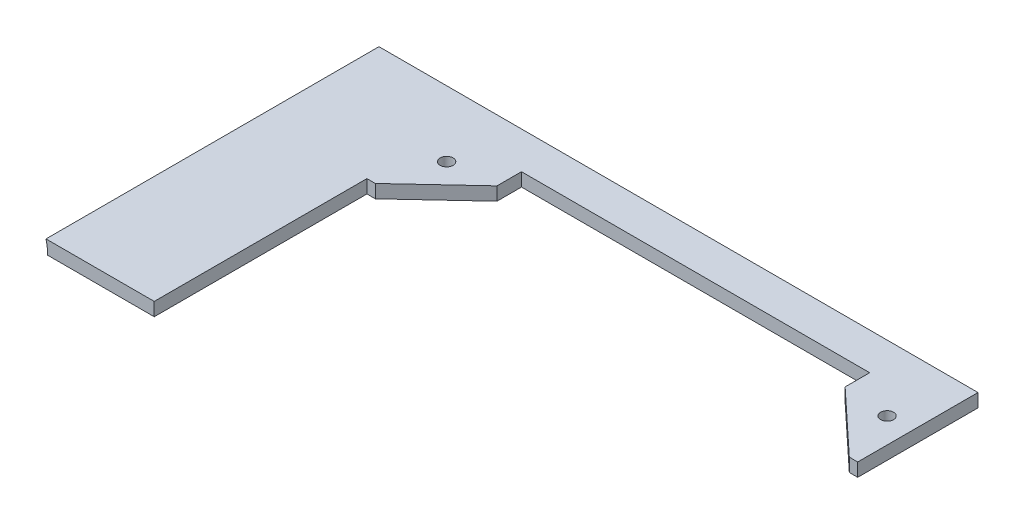
from build123d import *

# Parameters (mm, degrees)
SKETCH1_W            = 190.5
SKETCH1_H            = 76.2
BOSS_EXTRUDE1_DEPTH  = 3.175
SKETCH2_R            = 1.545336663
CUT_EXTRUDE4_DEPTH   = 4.175
SKETCH3_W            = 153.75
SKETCH3_H            = 3.175
BOSS_EXTRUDE2_DEPTH  = 3.175
CUT_SWEEP1_PROFILE_R = 12.7


with BuildPart() as part:
    # Sketch1 → Boss-Extrude1 (new body)
    with BuildSketch(Plane(origin=(0, 0, 0), x_dir=(1, 0, 0), z_dir=(0, 1, 0))):
        Rectangle(SKETCH1_W, SKETCH1_H)
    extrude(amount=BOSS_EXTRUDE1_DEPTH)

    # Sketch2 → Cut-Extrude4 (cut, through all)
    with BuildSketch(Plane(origin=(0, 3.175, 0), x_dir=(1, 0, 0), z_dir=(0, 1, 0))):
        Polygon((-58.5, 12.6), (-58.5, -38.1), (95.25, -38.1), (95.25, 38.1), (58.5, 38.1), (58.5, 12.6), (56.5, 12.6), (41.5, 26.6), (41.5, 32.45), (-41.5, 32.45), (-41.5, 26.6), (-56.5, 12.6), align=None)
        with Locations((-52.505245516, 25.605245516)):
            Circle(SKETCH2_R)
        with Locations((52.5, 25.605245516)):
            Circle(SKETCH2_R)
    extrude(amount=-CUT_EXTRUDE4_DEPTH, mode=Mode.SUBTRACT)

    # Sketch3 → Boss-Extrude2 (add)
    with BuildSketch(Plane(origin=(0, 0, -38.1), x_dir=(-1, 0, 0), z_dir=(0, 0, -1))):
        with Locations((18.375, 1.5875)):
            Rectangle(SKETCH3_W, SKETCH3_H)
    extrude(amount=BOSS_EXTRUDE2_DEPTH)

    # Cut-Sweep1: sweep along a curve in space
    with BuildLine() as cut_sweep1_path:
        Line((-96.6, 0, -54.083912637), (-96.6, 0, 450.454630794))
    # Cut-Sweep1 profile (on start of the path) → Cut-Sweep1 (sweep, cut)
    with BuildSketch(Plane(origin=(-96.6, 0, -54.083912637), x_dir=(0, 1, 0), z_dir=(0, 0, 1))):
        Circle(CUT_SWEEP1_PROFILE_R)
    sweep(path=cut_sweep1_path.line, mode=Mode.SUBTRACT)


solid = part.part
